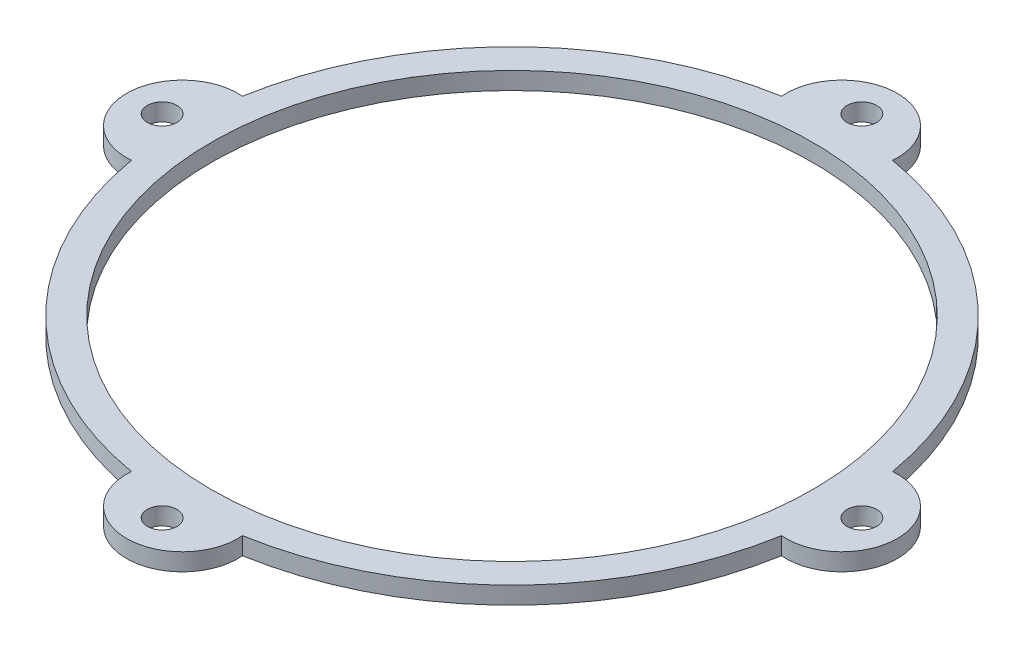
from build123d import *

# Parameters (mm, degrees)
SKETCH3_W           = 236.719908988
SKETCH3_H           = 211.092865268
BOSS_EXTRUDE2_DEPTH = 2
SKETCH4_R           = 34.5
CUT_EXTRUDE2_DEPTH  = 2
SKETCH5_W           = 236.719908988
SKETCH5_H           = 211.092865268
CUT_EXTRUDE3_DEPTH  = 2
SKETCH6_R           = 1.7
CUT_EXTRUDE4_DEPTH  = 2


with BuildPart() as part:
    # Sketch3 → Boss-Extrude2 (new body)
    with BuildSketch(Plane(origin=(0, 0, 0), x_dir=(1, 0, 0), z_dir=(0, 1, 0))):
        Rectangle(SKETCH3_W, SKETCH3_H)
    extrude(amount=BOSS_EXTRUDE2_DEPTH)

    # Sketch4 → Cut-Extrude2 (cut)
    with BuildSketch(Plane(origin=(0, 2, 0), x_dir=(1, 0, 0), z_dir=(0, 1, 0))):
        Circle(SKETCH4_R)
    extrude(amount=-CUT_EXTRUDE2_DEPTH, mode=Mode.SUBTRACT)

    # Sketch5 → Cut-Extrude3 (cut)
    with BuildSketch(Plane(origin=(0, 2, 0), x_dir=(1, 0, 0), z_dir=(0, 1, 0))):
        Rectangle(SKETCH5_W, SKETCH5_H)
        with BuildLine():
            ThreePointArc((6.370089382, 37.28475005), (26.746313998, 26.746313998), (37.28475005, 6.370089382))
            ThreePointArc((37.28475005, 6.370089382), (44.217957746, 0), (37.28475005, -6.370089382))
            ThreePointArc((37.28475005, -6.370089382), (26.746313998, -26.746313998), (6.370089382, -37.28475005))
            ThreePointArc((6.370089382, -37.28475005), (0, -44.217957746), (-6.370089382, -37.28475005))
            ThreePointArc((-6.370089382, -37.28475005), (-26.746313998, -26.746313998), (-37.28475005, -6.370089382))
            ThreePointArc((-37.28475005, -6.370089382), (-44.217957746, 0), (-37.28475005, 6.370089382))
            ThreePointArc((-37.28475005, 6.370089382), (-26.746313998, 26.746313998), (-6.370089382, 37.28475005))
            ThreePointArc((-6.370089382, 37.28475005), (0, 44.217957746), (6.370089382, 37.28475005))
        make_face(mode=Mode.SUBTRACT)
    extrude(amount=-CUT_EXTRUDE3_DEPTH, mode=Mode.SUBTRACT)

    # Sketch6 → Cut-Extrude4 (cut)
    with BuildSketch(Plane(origin=(0, 2, 0), x_dir=(1, 0, 0), z_dir=(0, 1, 0))):
        with Locations((0, 40.133145431)):
            Circle(SKETCH6_R)
        with Locations((-40.133145431, 0)):
            Circle(SKETCH6_R)
        with Locations((0, -40.133145431)):
            Circle(SKETCH6_R)
        with Locations((40.133145431, 0)):
            Circle(SKETCH6_R)
    extrude(amount=-CUT_EXTRUDE4_DEPTH, mode=Mode.SUBTRACT)


solid = part.part
